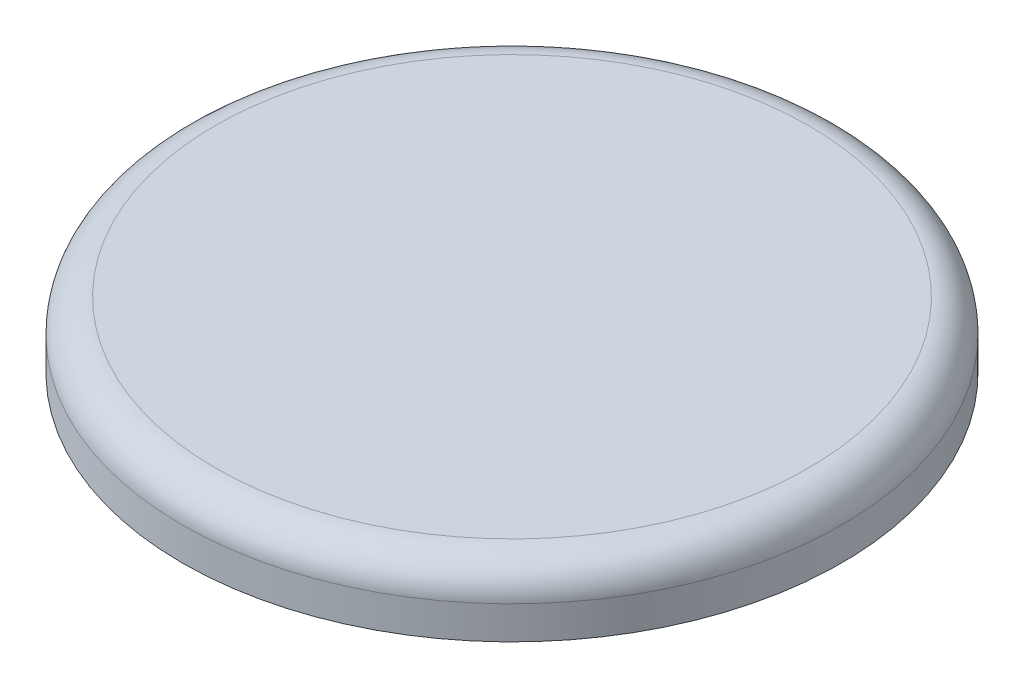
from build123d import *

# Parameters (mm, degrees)
SKETCH1_R           = 10
BOSS_EXTRUDE1_DEPTH = 2
FILLET1_R           = 1


with BuildPart() as part:
    # Sketch1 → Boss-Extrude1 (new body)
    with BuildSketch(Plane(origin=(0, 0, 0), x_dir=(1, 0, 0), z_dir=(0, 1, 0))):
        Circle(SKETCH1_R)
    extrude(amount=BOSS_EXTRUDE1_DEPTH)

    # Fillet1
    fillet1_edges = [part.edges().sort_by_distance(p)[0] for p in [
        (-10, 2, 0),
    ]]
    fillet(fillet1_edges, radius=FILLET1_R)


solid = part.part
